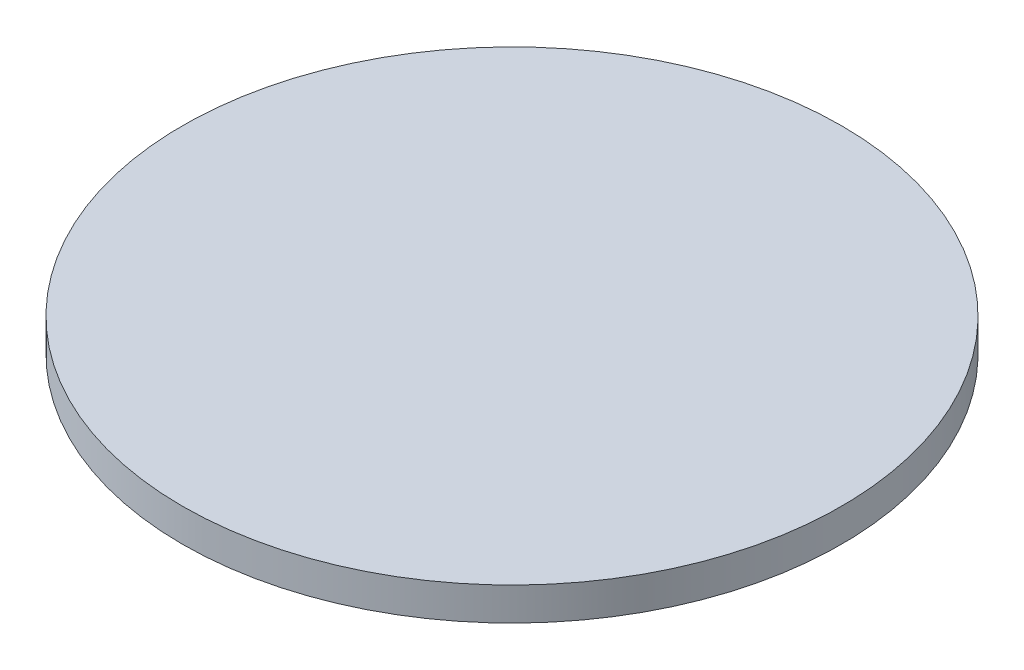
from build123d import *

# Parameters (mm, degrees)
SKETCH1_R           = 50
BOSS_EXTRUDE1_DEPTH = 5


with BuildPart() as part:
    # Sketch1 → Boss-Extrude1 (new body)
    with BuildSketch(Plane(origin=(0, 0, 0), x_dir=(1, 0, 0), z_dir=(0, 1, 0))):
        Circle(SKETCH1_R)
    extrude(amount=BOSS_EXTRUDE1_DEPTH)


solid = part.part
